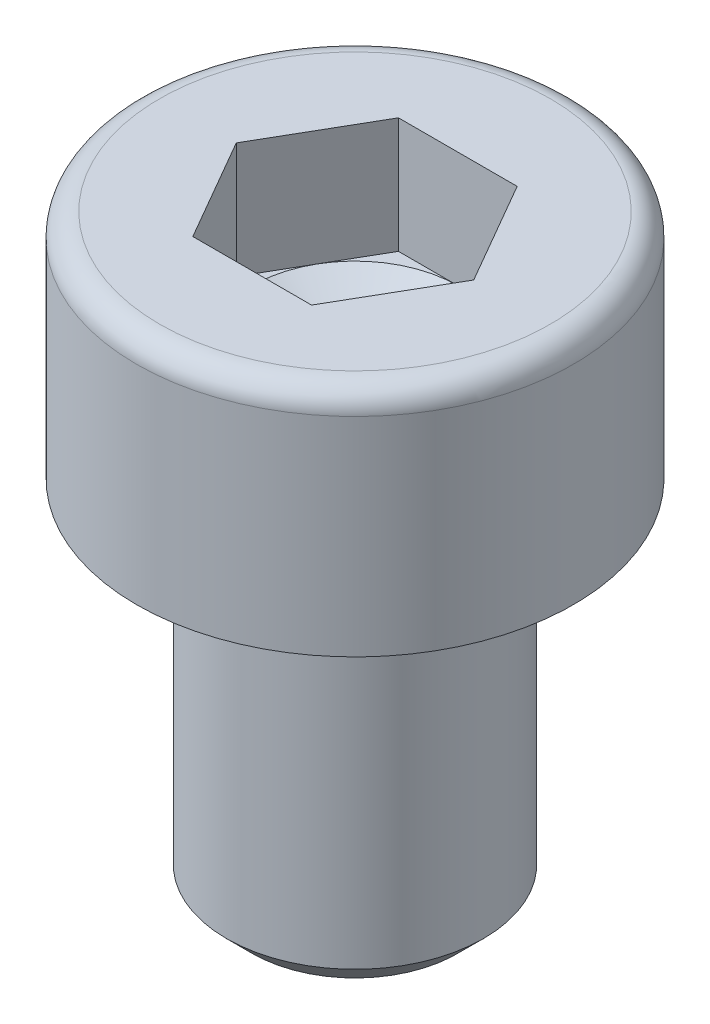
from build123d import *

# Parameters (mm, degrees)
ESQUISSE2_R             = 2.5
BASE_EXTRUSION_DEPTH    = 7
CHANFREIN1_SIZE         = 0.5
ENL_V_MAT_EXTRU_1_DEPTH = 2.25


with BuildPart() as part:
    # Esquisse2 → Base-Extrusion (new body)
    with BuildSketch(Plane(origin=(0, 0, 0), x_dir=(1, 0, 0), z_dir=(0, 1, 0))):
        with Locations(Location((0, 0, 0), (0, 0, 270))):  # turned: the seam where the file's is
            Circle(ESQUISSE2_R)
    extrude(amount=-BASE_EXTRUSION_DEPTH)

    # Chanfrein1
    chanfrein1_edges = [part.edges().sort_by_distance(p)[0] for p in [
        (0, -7, -2.5),
    ]]
    chamfer(chanfrein1_edges, length=CHANFREIN1_SIZE)

    # Esquisse5 → Boss.-Révol.1 (revolve)
    with BuildSketch(Plane.XY, mode=Mode.PRIVATE) as boss_r_vol_1_sk:
        with BuildLine():
            Line((2, 4.5), (2, 2.25))
            Line((2, 2.25), (0, 1.095299462))
            Line((0, 1.095299462), (0, 0))
            Line((0, 0), (4.25, 0))
            Line((4.25, 0), (4.25, 4.05))
            ThreePointArc((4.25, 4.05), (4.118198052, 4.368198052), (3.8, 4.5))
            Line((3.8, 4.5), (2, 4.5))
        make_face()
    revolve(boss_r_vol_1_sk.sketch.rotate(Axis((0, 4.5, 0), (0, -1, 0)), 90), axis=Axis((0, 4.5, 0), (0, -1, 0)))  # turned: the seam where the file's is

    # Esquisse7 → Enlèv. mat.-Extru.1 (cut)
    with BuildSketch(Plane(origin=(0, 4.5, 0), x_dir=(-1, 0, 0), z_dir=(0, 1, 0))):
        Polygon((1.154700538, 2), (-1.154700538, 2), (-2.309401077, 0), (-1.154700538, -2), (1.154700538, -2), (2.309401077, 0), align=None)
    extrude(amount=-ENL_V_MAT_EXTRU_1_DEPTH, mode=Mode.SUBTRACT)


solid = part.part
